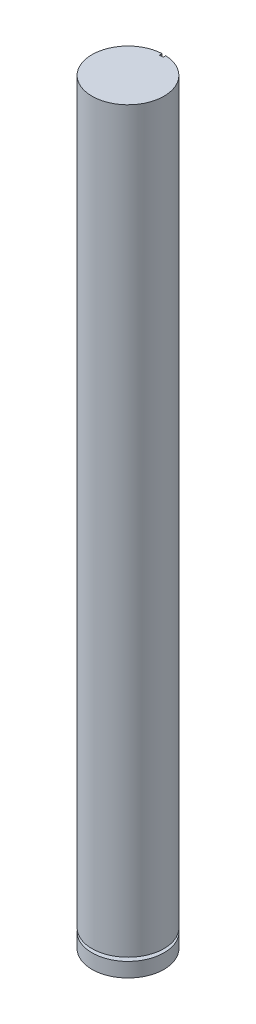
from build123d import *

# Parameters (mm, degrees)
SKETCH2_R           = 20
BOSS_EXTRUDE1_DEPTH = 420
SKETCH3_W           = 5
SKETCH3_H           = 2
SKETCH4_W           = 2
SKETCH4_H           = 1.5
CUT_EXTRUDE2_DEPTH  = 30


with BuildPart() as part:
    # Sketch2 → Boss-Extrude1 (new body)
    with BuildSketch(Plane(origin=(0, 0, 0), x_dir=(1, 0, 0), z_dir=(0, 1, 0))):
        Circle(SKETCH2_R)
    extrude(amount=BOSS_EXTRUDE1_DEPTH)

    # Sketch3 → Cut-Revolve1 (revolve, cut)
    with BuildSketch(Plane(origin=(0, 0, 0), x_dir=(0, 0, -1), z_dir=(1, 0, 0))):
        with Locations((17.5, 9)):
            Rectangle(SKETCH3_W, SKETCH3_H)
    revolve(axis=Axis((0, 0, 0), (0, 1, 0)), mode=Mode.SUBTRACT)

    # Sketch4 → Cut-Extrude2 (cut)
    with BuildSketch(Plane(origin=(0, 420, 0), x_dir=(1, 0, 0), z_dir=(0, 1, 0))):
        with Locations((0, 19.25)):
            Rectangle(SKETCH4_W, SKETCH4_H)
    extrude(amount=-CUT_EXTRUDE2_DEPTH, mode=Mode.SUBTRACT)


solid = part.part
